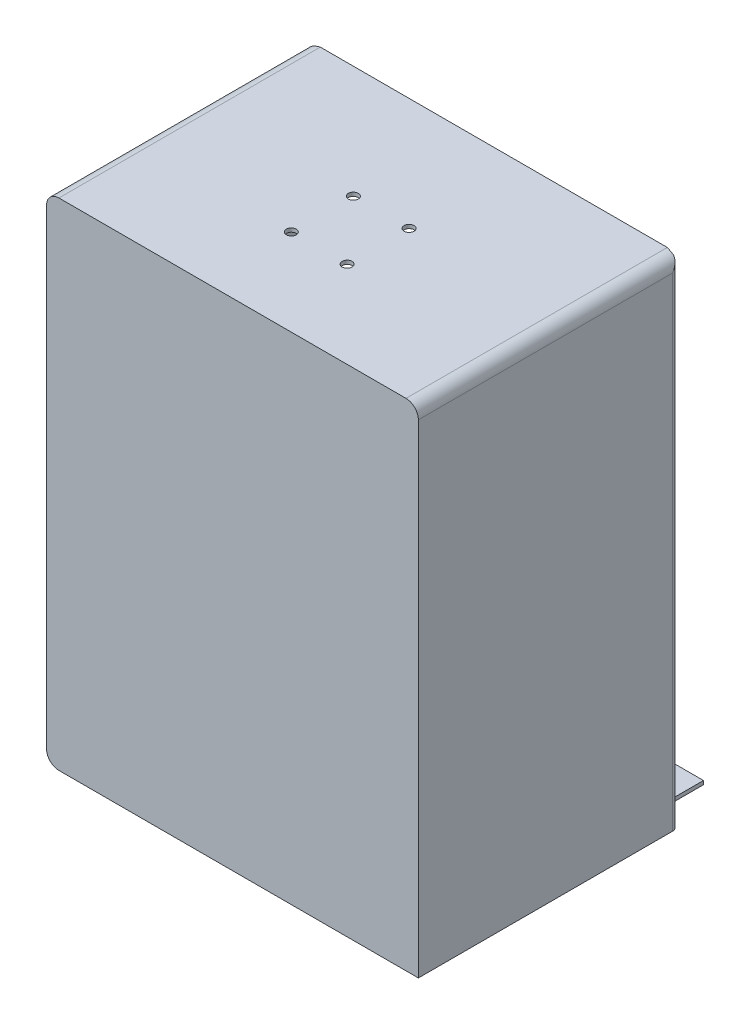
from build123d import *

# Parameters (mm, degrees)
BOSS_EXTRUDE1_DEPTH = 250
SHELL1_T            = -3
SKETCH4_R           = 4
CUT_EXTRUDE1_DEPTH  = 401
CUT_EXTRUDE3_DEPTH  = 400
CUT_EXTRUDE4_DEPTH  = 414
SKETCH7_W           = 291.024636147
SKETCH7_H           = 48.584181262
CUT_EXTRUDE5_DEPTH  = 232


with BuildPart() as part:
    # Sketch2 → Boss-Extrude1 (new body)
    with BuildSketch(Plane.XY):
        with BuildLine():
            Line((-140, -200), (150, -200))
            Line((150, -200), (150, 190))
            ThreePointArc((150, 190), (147.071067812, 197.071067812), (140, 200))
            Line((140, 200), (-140, 200))
            ThreePointArc((-140, 200), (-147.071067812, 197.071067812), (-150, 190))
            Line((-150, 190), (-150, -190))
            ThreePointArc((-150, -190), (-147.071067812, -197.071067812), (-140, -200))
        make_face()
    extrude(amount=BOSS_EXTRUDE1_DEPTH)

    # Shell1
    shell1_openings = [part.faces().sort_by_distance(p)[0] for p in [
        (-20.29586683, 27.438723973, 0),
    ]]
    offset(amount=SHELL1_T, openings=shell1_openings, kind=Kind.INTERSECTION)

    # Sketch4 → Cut-Extrude1 (cut, through all)
    with BuildSketch(Plane(origin=(0, 200, 0), x_dir=(1, 0, 0), z_dir=(0, 1, 0))):
        with Locations((-22.5, -130)):
            Circle(SKETCH4_R)
        with Locations((22.5, -130)):
            Circle(SKETCH4_R)
        with Locations((-22.5, -180)):
            Circle(SKETCH4_R)
        with Locations((22.5, -180)):
            Circle(SKETCH4_R)
    extrude(amount=-CUT_EXTRUDE1_DEPTH, mode=Mode.SUBTRACT)

    # Sketch6 → Cut-Extrude3 (cut)
    with BuildSketch(Plane(origin=(0, 200, 0), x_dir=(1, 0, 0), z_dir=(0, 1, 0))):
        with BuildLine():
            Line((-140, -39.142135624), (-140, 0))
            Line((-140, 0), (-150, 0))
            Line((-150, 0), (-150, -45))
            ThreePointArc((-150, -45), (-148.535533906, -41.464466094), (-145, -40))
            ThreePointArc((-145, -40), (-142.463470319, -39.783978395), (-140, -39.142135624))
        make_face()
    cut_extrude3 = extrude(amount=-CUT_EXTRUDE3_DEPTH, mode=Mode.SUBTRACT)

    # Sketch6_3 → Cut-Extrude4 (cut)
    with BuildSketch(Plane(origin=(0, 200, 0), x_dir=(1, 0, 0), z_dir=(0, 1, 0))):
        with BuildLine():
            Line((-130, -25), (-130, 0))
            Line((-130, 0), (-140, 0))
            Line((-140, 0), (-140, -39.142135624))
            ThreePointArc((-140, -39.142135624), (-132.752551286, -33.660254038), (-130, -25))
        make_face()
    cut_extrude4 = extrude(amount=-CUT_EXTRUDE4_DEPTH, mode=Mode.SUBTRACT)

    # Mirror1: Cut-Extrude3, Cut-Extrude4 across plane
    add(cut_extrude3.mirror(Plane(origin=(0, 0, 0), x_dir=(0, 0, 1), z_dir=(1, 0, 0))), mode=Mode.SUBTRACT)
    add(cut_extrude4.mirror(Plane(origin=(0, 0, 0), x_dir=(0, 0, 1), z_dir=(1, 0, 0))), mode=Mode.SUBTRACT)

    # Sketch7 → Cut-Extrude5 (cut)
    with BuildSketch(Plane(origin=(0, 200, 0), x_dir=(1, 0, 0), z_dir=(0, 1, 0))):
        with Locations((5.512318073, -14.850044993)):
            Rectangle(SKETCH7_W, SKETCH7_H)
    extrude(amount=-CUT_EXTRUDE5_DEPTH, mode=Mode.SUBTRACT)


solid = part.part
